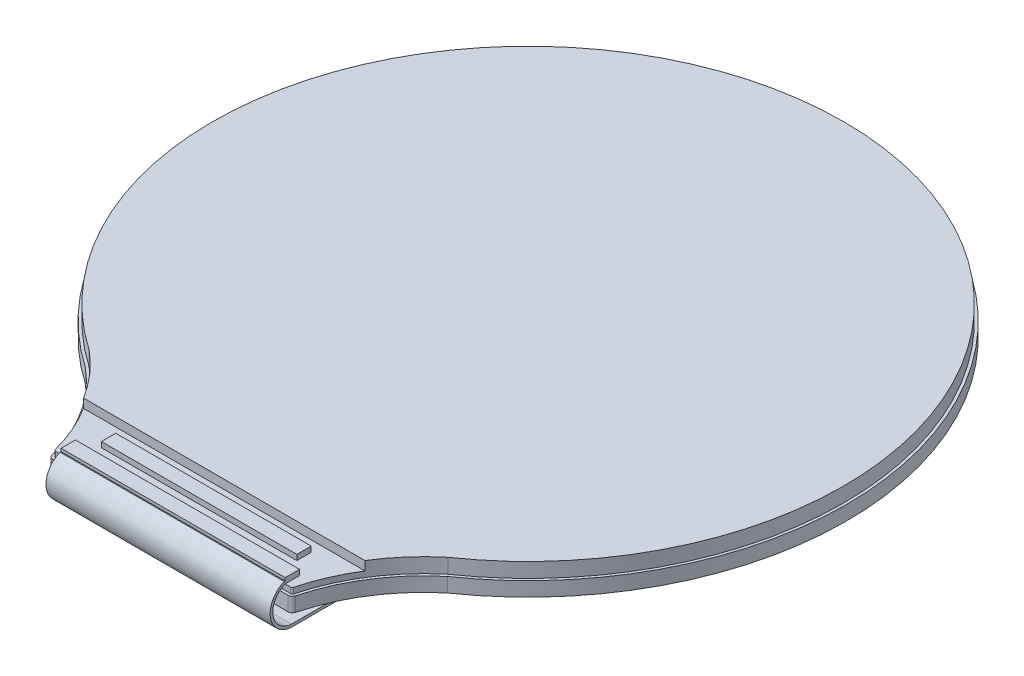
from build123d import *

# Parameters (mm, degrees)
BOSS_EXTRUDE1_DEPTH = 0.8
FILLET1_R           = 0.25
BOSS_EXTRUDE2_DEPTH = 0.82
SKETCH4_W           = 20
SKETCH4_H           = 3
CUT_EXTRUDE1_DEPTH  = 0.5
SKETCH5_W           = 10.9
SKETCH5_H           = 0.8
SKETCH5_W_2         = 12.5
BOSS_EXTRUDE3_DEPTH = 0.3
CUT_EXTRUDE2_DEPTH  = 0.001
BOSS_EXTRUDE4_DEPTH = 6.25
SKETCH9_R           = 0.5
CUT_EXTRUDE3_DEPTH  = 0.2
CUT_EXTRUDE4_DEPTH  = 0.2
FILLET2_R           = 0.5
FILLET3_R           = 0.5
SKETCH11_W          = 0.5
SKETCH11_H          = 2
CUT_EXTRUDE5_DEPTH  = 0.01


with BuildPart() as part:
    # Sketch1 → Boss-Extrude1 (new body)
    with BuildSketch(Plane(origin=(0, 0, 0), x_dir=(1, 0, 0), z_dir=(0, 1, 0))):
        with BuildLine():
            ThreePointArc((-10.098638625, -14.597259946), (-7.990776159, -17.002408255), (-6.75, -19.95))
            Line((-6.75, -19.95), (6.75, -19.95))
            ThreePointArc((6.75, -19.95), (7.990776159, -17.002408255), (10.098638625, -14.597259946))
            ThreePointArc((10.098638625, -14.597259946), (0, 17.75), (-10.098638625, -14.597259946))
        make_face()
    extrude(amount=BOSS_EXTRUDE1_DEPTH)

    # Fillet1
    fillet1_edges = [part.edges().sort_by_distance(p)[0] for p in [
        (6.75, 0.4, 19.95),
        (-6.75, 0.4, 19.95),
    ]]
    fillet(fillet1_edges, radius=FILLET1_R)

    # Sketch2 → Boss-Extrude2 (add)
    with BuildSketch(Plane(origin=(0, 0.8, 0), x_dir=(1, 0, 0), z_dir=(0, 1, 0))):
        with BuildLine():
            Line((-6.555315046, -19.8), (6.555315046, -19.8))
            ThreePointArc((6.555315046, -19.8), (6.616378729, -19.779191076), (6.652029022, -19.725424532))
            ThreePointArc((6.652029022, -19.725424532), (7.917501546, -16.837654003), (10.008059541, -14.477525487))
            ThreePointArc((10.008059541, -14.477525487), (0, 17.6), (-10.008059541, -14.477525487))
            ThreePointArc((-10.008059541, -14.477525487), (-7.917501546, -16.837654003), (-6.652029022, -19.725424532))
            ThreePointArc((-6.652029022, -19.725424532), (-6.616378729, -19.779191076), (-6.555315046, -19.8))
        make_face()
    extrude(amount=BOSS_EXTRUDE2_DEPTH)

    # Sketch4 → Cut-Extrude1 (cut)
    with BuildSketch(Plane(origin=(0, 1.62, 0), x_dir=(1, 0, 0), z_dir=(0, 1, 0))):
        with Locations((0, -18.45)):
            Rectangle(SKETCH4_W, SKETCH4_H)
    extrude(amount=-CUT_EXTRUDE1_DEPTH, mode=Mode.SUBTRACT)

    # Sketch5 → Boss-Extrude3 (add)
    with BuildSketch(Plane(origin=(0, 1.12, 0), x_dir=(1, 0, 0), z_dir=(0, 1, 0))):
        with Locations((0, -17.95)):
            Rectangle(SKETCH5_W, SKETCH5_H)
        with Locations((0, -19.4)):
            Rectangle(SKETCH5_W_2, SKETCH5_H)
    extrude(amount=BOSS_EXTRUDE3_DEPTH)

    # Sketch6 → Cut-Extrude2 (cut)
    with BuildSketch(Plane.XZ):
        with BuildLine():
            Line((-8.115384615, -4), (-7.730769231, -4))
            Line((-7.730769231, -4), (-7.730769231, -5.423878205))
            add(Edge.make_bspline(
                [(-7.730769231, -5.423878205), (-7.713359057, -5.406155063), (-7.678704871, -5.370877927), (-7.623058077, -5.32222958), (-7.565824024, -5.276296318), (-7.506110478, -5.234127463), (-7.443693535, -5.196058157), (-7.379151545, -5.161348193), (-7.312721311, -5.129184198), (-7.266695291, -5.111461223), (-7.243589744, -5.102564103)],
                knots=[0, 0, 0, 0, 7.4507e-05, 0.000148304, 0.000221573, 0.000294602, 0.000367437, 0.000440755, 0.000514409, 0.000588657, 0.000588657, 0.000588657, 0.000588657], degree=3))
            Line((-7.243589744, -5.102564103), (-7.243589744, -5.487179487))
            add(Edge.make_bspline(
                [(-7.243589744, -5.487179487), (-7.269206127, -5.496780125), (-7.322819224, -5.516873513), (-7.4019898, -5.559745442), (-7.484809813, -5.612481575), (-7.55429821, -5.664291811), (-7.608950479, -5.710784433), (-7.647434139, -5.747742278), (-7.683081921, -5.785759046), (-7.71458346, -5.825869891), (-7.742738811, -5.867294969), (-7.767686987, -5.909958484), (-7.789646776, -5.953997327), (-7.801142624, -5.984664925), (-7.806891026, -6)],
                knots=[0, 0, 0, 0, 8.1986e-05, 0.00017159, 0.000269396, 0.000376448, 0.000431289, 0.00048456, 0.000536441, 0.000587499, 0.000637393, 0.000686592, 0.000735686, 0.000784789, 0.000784789, 0.000784789, 0.000784789], degree=3))
            Line((-7.806891026, -6), (-8.115384615, -6))
            Line((-8.115384615, -6), (-8.115384615, -4))
        make_face()
        with BuildLine():
            add(Edge.make_bspline(
                [(-6.256410256, -6), (-6.280217696, -5.999427681), (-6.326568051, -5.998313441), (-6.394092675, -5.988384763), (-6.457597842, -5.972630411), (-6.517095807, -5.949873464), (-6.572889159, -5.921071609), (-6.624192861, -5.884945541), (-6.672194832, -5.843249183), (-6.699906098, -5.810871154), (-6.713942308, -5.794471154)],
                knots=[0, 0, 0, 0, 7.1386e-05, 0.000138981, 0.000204279, 0.000267302, 0.000329663, 0.000392123, 0.00045514, 0.000519821, 0.000519821, 0.000519821, 0.000519821], degree=3))
            add(Edge.make_bspline(
                [(-6.713942308, -5.794471154), (-6.721971706, -5.784027534), (-6.738358302, -5.762713937), (-6.760427113, -5.728273453), (-6.781644323, -5.691739969), (-6.800160808, -5.652232771), (-6.817907535, -5.610442711), (-6.834289066, -5.566253586), (-6.848753793, -5.519415687), (-6.861363445, -5.470142284), (-6.873150438, -5.418358482), (-6.883024897, -5.363937998), (-6.891475748, -5.30701848), (-6.898066216, -5.247662035), (-6.903975014, -5.185984989), (-6.907208178, -5.12168565), (-6.909857159, -5.054909676), (-6.910121795, -5.009484858), (-6.91025641, -4.986378205)],
                knots=[0, 0, 0, 0, 3.9503e-05, 8.0619e-05, 0.00012261, 0.000166155, 0.000211397, 0.000258805, 0.000307466, 0.000358385, 0.000411358, 0.000466758, 0.000524268, 0.000583953, 0.000645906, 0.00071011, 0.00077706, 0.000846375, 0.000846375, 0.000846375, 0.000846375], degree=3))
            add(Edge.make_bspline(
                [(-6.91025641, -4.986378205), (-6.910123823, -4.963271499), (-6.90986394, -4.917980046), (-6.907198306, -4.851338037), (-6.903972131, -4.787172759), (-6.898079986, -4.725492419), (-6.891426237, -4.666147773), (-6.883215148, -4.60929205), (-6.872578164, -4.55512162), (-6.860964857, -4.503420376), (-6.848435539, -4.453937659), (-6.833327892, -4.407184318), (-6.817607087, -4.362444446), (-6.799447896, -4.320600625), (-6.780266949, -4.28104453), (-6.759365469, -4.244138144), (-6.737050241, -4.209484218), (-6.720505114, -4.188058179), (-6.712339744, -4.177483974)],
                knots=[0, 0, 0, 0, 6.9316e-05, 0.000135865, 0.000200069, 0.000262022, 0.000321707, 0.000379217, 0.000434297, 0.00048727, 0.000538189, 0.000587352, 0.000634623, 0.000680391, 0.00072411, 0.000766449, 0.000807565, 0.00084763, 0.00084763, 0.00084763, 0.00084763], degree=3))
            add(Edge.make_bspline(
                [(-6.712339744, -4.177483974), (-6.698431943, -4.161224555), (-6.670977274, -4.129127677), (-6.623506763, -4.087776928), (-6.572285892, -4.052396891), (-6.516593565, -4.024171814), (-6.45738522, -4.001262035), (-6.3937766, -3.986013097), (-6.32643646, -3.976064142), (-6.280085266, -3.974935471), (-6.256410256, -3.974358974)],
                knots=[0, 0, 0, 0, 6.4115e-05, 0.000126566, 0.000188242, 0.000250418, 0.000313441, 0.000378254, 0.000446245, 0.000517231, 0.000517231, 0.000517231, 0.000517231], degree=3))
            add(Edge.make_bspline(
                [(-6.256410256, -3.974358974), (-6.232465306, -3.975047809), (-6.185543935, -3.976397615), (-6.117038725, -3.987102948), (-6.05191365, -4.004240276), (-5.990438846, -4.02875213), (-5.932500524, -4.060395455), (-5.878230627, -4.098928669), (-5.828012004, -4.1449143), (-5.788771275, -4.187788789), (-5.760262586, -4.226505545), (-5.739643325, -4.258394149), (-5.720472285, -4.29299406), (-5.703437474, -4.330736183), (-5.686809514, -4.370661161), (-5.672137696, -4.413526128), (-5.65898602, -4.459031002), (-5.646793755, -4.507214043), (-5.636697895, -4.558359763), (-5.627313567, -4.612021724), (-5.619863903, -4.668448556), (-5.613356728, -4.727475057), (-5.608740431, -4.78935478), (-5.604999189, -4.853860171), (-5.603121636, -4.921196211), (-5.602752435, -4.967013016), (-5.602564103, -4.990384615)],
                knots=[0, 0, 0, 0, 7.1805e-05, 0.000140706, 0.00020747, 0.000273461, 0.000338721, 0.000405088, 0.000472599, 0.00054267, 0.000579049, 0.000616722, 0.00065653, 0.00069758, 0.000740881, 0.00078624, 0.000833403, 0.00088296, 0.000935289, 0.00098976, 0.001046364, 0.001106005, 0.00116789, 0.001232494, 0.001299832, 0.001369949, 0.001369949, 0.001369949, 0.001369949], degree=3))
            add(Edge.make_bspline(
                [(-5.602564103, -4.990384615), (-5.602695692, -5.013357851), (-5.602953589, -5.058382439), (-5.605637797, -5.124756264), (-5.608824425, -5.188657348), (-5.614769652, -5.250199621), (-5.621368662, -5.309281919), (-5.629593905, -5.366008127), (-5.640430063, -5.419965061), (-5.651128206, -5.471752379), (-5.664608128, -5.520863014), (-5.679458743, -5.5675812), (-5.69512742, -5.612221036), (-5.713471985, -5.653848491), (-5.732541897, -5.693319606), (-5.753458016, -5.730219515), (-5.77576956, -5.764875072), (-5.792315163, -5.786300899), (-5.800480769, -5.796875)],
                knots=[0, 0, 0, 0, 6.8915e-05, 0.000135064, 0.000199268, 0.000260822, 0.000320507, 0.000377621, 0.000432701, 0.000485587, 0.000536222, 0.000585385, 0.000632656, 0.000678056, 0.000721775, 0.000764114, 0.00080523, 0.000845294, 0.000845294, 0.000845294, 0.000845294], degree=3))
            add(Edge.make_bspline(
                [(-5.800480769, -5.796875), (-5.814389335, -5.813132855), (-5.841845514, -5.845226646), (-5.889304971, -5.886599997), (-5.940469275, -5.921827975), (-5.99599909, -5.950394985), (-6.055343477, -5.972994929), (-6.11903545, -5.98836653), (-6.186386321, -5.998289296), (-6.232736014, -5.999421632), (-6.256410256, -6)],
                knots=[0, 0, 0, 0, 6.4115e-05, 0.000126566, 0.000188242, 0.000250062, 0.00031346, 0.000378272, 0.000446263, 0.000517249, 0.000517249, 0.000517249, 0.000517249], degree=3))
        make_face()
        with BuildLine():
            add(Edge.make_bspline(
                [(-6.256410256, -5.666666667), (-6.244074324, -5.666136157), (-6.219933376, -5.665097971), (-6.184823503, -5.656632254), (-6.151661361, -5.643519267), (-6.120545281, -5.624261411), (-6.091728132, -5.598186166), (-6.067312377, -5.562952189), (-6.046205369, -5.519763078), (-6.035646151, -5.487472), (-6.030048077, -5.470352564)],
                knots=[0, 0, 0, 0, 3.6966e-05, 7.234e-05, 0.000107753, 0.000143554, 0.000181554, 0.00022347, 0.000271309, 0.00032529, 0.00032529, 0.00032529, 0.00032529], degree=3))
            add(Edge.make_bspline(
                [(-6.030048077, -5.470352564), (-6.026551497, -5.457436105), (-6.01903642, -5.429675215), (-6.01051141, -5.38441298), (-6.003442602, -5.332915663), (-5.99758639, -5.275446586), (-5.992677421, -5.211868318), (-5.989731855, -5.142249731), (-5.987667073, -5.066385187), (-5.987346341, -5.013756948), (-5.987179487, -4.986378205)],
                knots=[0, 0, 0, 0, 4.0132e-05, 8.6255e-05, 0.000138041, 0.000196046, 0.000259529, 0.000329314, 0.000405062, 0.000487197, 0.000487197, 0.000487197, 0.000487197], degree=3))
            add(Edge.make_bspline(
                [(-5.987179487, -4.986378205), (-5.987161379, -4.959132103), (-5.987126666, -4.90690178), (-5.989476176, -4.83198716), (-5.991807619, -4.76369156), (-5.996558042, -4.702019094), (-6.001188096, -4.646875537), (-6.008340993, -4.598577808), (-6.015397388, -4.556683035), (-6.027530885, -4.511311525), (-6.044043928, -4.463608126), (-6.066433453, -4.415139825), (-6.092028856, -4.377296398), (-6.120929179, -4.349523173), (-6.152548815, -4.331310842), (-6.18495109, -4.316809368), (-6.220172356, -4.309539108), (-6.244232295, -4.308312936), (-6.256410256, -4.307692308)],
                knots=[0, 0, 0, 0, 8.1732e-05, 0.000156678, 0.000224845, 0.000286701, 0.000342234, 0.000390791, 0.000433148, 0.000469588, 0.000531548, 0.000584411, 0.000629312, 0.000667857, 0.000703448, 0.000738274, 0.000773951, 0.000810517, 0.000810517, 0.000810517, 0.000810517], degree=3))
            add(Edge.make_bspline(
                [(-6.256410256, -4.307692308), (-6.268605933, -4.308251161), (-6.292730095, -4.309356625), (-6.327794027, -4.317549183), (-6.360909019, -4.33106869), (-6.392234707, -4.349941747), (-6.421078872, -4.376196766), (-6.445512464, -4.41139911), (-6.466613831, -4.454598224), (-6.477173907, -4.486887781), (-6.482772436, -4.50400641)],
                knots=[0, 0, 0, 0, 3.6566e-05, 7.2331e-05, 0.000107373, 0.000143515, 0.000181515, 0.000223431, 0.00027127, 0.000325251, 0.000325251, 0.000325251, 0.000325251], degree=3))
            add(Edge.make_bspline(
                [(-6.482772436, -4.50400641), (-6.486263756, -4.516923915), (-6.493733321, -4.544560491), (-6.502322901, -4.589540582), (-6.509375473, -4.640641815), (-6.51525811, -4.697841463), (-6.52013883, -4.761289181), (-6.523090003, -4.830907185), (-6.525149199, -4.906638403), (-6.52547298, -4.959133037), (-6.525641026, -4.986378205)],
                knots=[0, 0, 0, 0, 4.0132e-05, 8.5861e-05, 0.000137251, 0.000194857, 0.000258341, 0.000328126, 0.000403874, 0.000485608, 0.000485608, 0.000485608, 0.000485608], degree=3))
            add(Edge.make_bspline(
                [(-6.525641026, -4.986378205), (-6.525413648, -5.013621499), (-6.524977804, -5.065842323), (-6.523721733, -5.140928013), (-6.520219482, -5.209290888), (-6.516675159, -5.271199223), (-6.510797662, -5.326327328), (-6.504884367, -5.374956963), (-6.496733827, -5.416755552), (-6.485614863, -5.462220605), (-6.468787452, -5.509798478), (-6.445744029, -5.557829344), (-6.420860175, -5.596382268), (-6.391848323, -5.624292649), (-6.360411507, -5.64336715), (-6.32750697, -5.656728862), (-6.292608623, -5.665047942), (-6.26860887, -5.666121167), (-6.256410256, -5.666666667)],
                knots=[0, 0, 0, 0, 8.1735e-05, 0.000156672, 0.000225256, 0.000287085, 0.000342657, 0.000391557, 0.000433987, 0.000470328, 0.00053191, 0.000584948, 0.000629951, 0.000668772, 0.000704573, 0.000739615, 0.00077499, 0.000811556, 0.000811556, 0.000811556, 0.000811556], degree=3))
        make_face(mode=Mode.SUBTRACT)
        Polygon((-5.423076923, -4), (-5.015224359, -4), (-4.846554487, -4.461538462), (-4.078926282, -4.461538462), (-3.91025641, -4), (-3.5, -4), (-4.256009615, -6), (-4.663461538, -6), align=None)
        Polygon((-4.724358974, -4.794871795), (-4.461538462, -5.512820513), (-4.199519231, -4.794871795), align=None, mode=Mode.SUBTRACT)
        with BuildLine():
            Line((-2.115384615, -4.49599359), (-2.5, -4.538461538))
            add(Edge.make_bspline(
                [(-2.5, -4.538461538), (-2.502538885, -4.520057279), (-2.507337899, -4.48526945), (-2.522285404, -4.437439312), (-2.54216032, -4.396898583), (-2.567843688, -4.363987158), (-2.598596488, -4.338666081), (-2.633777288, -4.320052272), (-2.673970178, -4.309692804), (-2.702132462, -4.308375763), (-2.716746795, -4.307692308)],
                knots=[0, 0, 0, 0, 5.5656e-05, 0.000105201, 0.000149636, 0.000190433, 0.000229419, 0.000268306, 0.000308927, 0.000352745, 0.000352745, 0.000352745, 0.000352745], degree=3))
            add(Edge.make_bspline(
                [(-2.716746795, -4.307692308), (-2.726264256, -4.307910874), (-2.745073481, -4.308342822), (-2.772569696, -4.314517468), (-2.799140429, -4.322985849), (-2.824370626, -4.335985264), (-2.848846756, -4.351743057), (-2.871654346, -4.371896397), (-2.893984694, -4.394780241), (-2.915096397, -4.422003377), (-2.934718225, -4.454817168), (-2.952114602, -4.494579272), (-2.968093633, -4.541438651), (-2.981335457, -4.59596416), (-2.993225745, -4.657615379), (-3.00357851, -4.726575181), (-3.011975253, -4.802890254), (-3.015686916, -4.856286978), (-3.017628205, -4.884214744)],
                knots=[0, 0, 0, 0, 2.8491e-05, 5.6306e-05, 8.4178e-05, 0.00011195, 0.000141175, 0.00017129, 0.000203024, 0.000237003, 0.000274381, 0.000317419, 0.000366958, 0.000422733, 0.000485592, 0.000555285, 0.00063187, 0.000715849, 0.000715849, 0.000715849, 0.000715849], degree=3))
            add(Edge.make_bspline(
                [(-3.017628205, -4.884214744), (-3.005323968, -4.871008445), (-2.981064379, -4.84497031), (-2.94088495, -4.81080931), (-2.898104216, -4.782088841), (-2.852941039, -4.758939133), (-2.805866578, -4.740025738), (-2.75610689, -4.727584847), (-2.704354816, -4.719049159), (-2.668972825, -4.718318837), (-2.651041667, -4.717948718)],
                knots=[0, 0, 0, 0, 5.4116e-05, 0.000106698, 0.000157812, 0.000208344, 0.000258712, 0.000309631, 0.000361931, 0.000415671, 0.000415671, 0.000415671, 0.000415671], degree=3))
            add(Edge.make_bspline(
                [(-2.651041667, -4.717948718), (-2.631389048, -4.718527555), (-2.592586595, -4.719670419), (-2.535398826, -4.727541076), (-2.480618992, -4.74213349), (-2.42736586, -4.76048138), (-2.37676676, -4.785867209), (-2.327937001, -4.815968157), (-2.281307737, -4.8519055), (-2.237335783, -4.892933918), (-2.196359678, -4.937765794), (-2.160973039, -4.986895093), (-2.131354173, -5.039475315), (-2.106096161, -5.094759727), (-2.087522201, -5.153781745), (-2.073743079, -5.215815561), (-2.065754226, -5.281309026), (-2.064660641, -5.32610045), (-2.064102564, -5.348958333)],
                knots=[0, 0, 0, 0, 5.8961e-05, 0.000116414, 0.000172676, 0.000228813, 0.000285074, 0.000342109, 0.000400686, 0.000461354, 0.000522342, 0.000582609, 0.000642539, 0.000703151, 0.000764601, 0.000827786, 0.00089358, 0.000962147, 0.000962147, 0.000962147, 0.000962147], degree=3))
            add(Edge.make_bspline(
                [(-2.064102564, -5.348958333), (-2.064613441, -5.372756322), (-2.065615563, -5.419437794), (-2.074271451, -5.487520331), (-2.087794134, -5.552194191), (-2.106887038, -5.613418529), (-2.132376259, -5.670871787), (-2.162948424, -5.724832269), (-2.198735621, -5.775474654), (-2.240478353, -5.821470169), (-2.285872873, -5.863567601), (-2.334837533, -5.900203546), (-2.387094365, -5.930820341), (-2.442178805, -5.956264113), (-2.500504503, -5.975859516), (-2.561698574, -5.989823589), (-2.625820555, -5.998482045), (-2.669576922, -5.999487094), (-2.691907051, -6)],
                knots=[0, 0, 0, 0, 7.1369e-05, 0.000139996, 0.00020553, 0.000269392, 0.000331997, 0.000393716, 0.000455193, 0.000517611, 0.000579705, 0.000640683, 0.000700668, 0.000761082, 0.000822402, 0.000884893, 0.000949148, 0.001016114, 0.001016114, 0.001016114, 0.001016114], degree=3))
            add(Edge.make_bspline(
                [(-2.691907051, -6), (-2.716253581, -5.999332976), (-2.763994259, -5.998025022), (-2.833921865, -5.986962012), (-2.900361098, -5.968587282), (-2.963341859, -5.942473286), (-3.023497146, -5.910148387), (-3.079962711, -5.869539804), (-3.132759959, -5.821597219), (-3.182613405, -5.766773121), (-3.227985644, -5.703456773), (-3.266611797, -5.630270099), (-3.299468717, -5.54791691), (-3.325989358, -5.456217149), (-3.346712225, -5.35519528), (-3.361014872, -5.24485296), (-3.370585368, -5.125168416), (-3.37138179, -5.042221171), (-3.371794872, -4.999198718)],
                knots=[0, 0, 0, 0, 7.3006e-05, 0.000143156, 0.000211782, 0.000279338, 0.000347284, 0.000416213, 0.000487415, 0.000560881, 0.000638147, 0.00072042, 0.000808506, 0.000903715, 0.001006411, 0.00111758, 0.001237326, 0.001366363, 0.001366363, 0.001366363, 0.001366363], degree=3))
            add(Edge.make_bspline(
                [(-3.371794872, -4.999198718), (-3.37119747, -4.955510818), (-3.370043264, -4.871103974), (-3.360740665, -4.749249047), (-3.34599274, -4.636743389), (-3.324386686, -4.533750641), (-3.297039751, -4.440073605), (-3.263486735, -4.355599696), (-3.223525052, -4.280555236), (-3.177015193, -4.214981352), (-3.125332685, -4.158433263), (-3.070305111, -4.109047004), (-3.011304768, -4.067579812), (-2.948937943, -4.032964991), (-2.882230101, -4.007049674), (-2.812115441, -3.988272886), (-2.738402342, -3.976109923), (-2.68794914, -3.974949721), (-2.662259615, -3.974358974)],
                knots=[0, 0, 0, 0, 0.000131049, 0.000253192, 0.0003664, 0.000471221, 0.000568577, 0.000658821, 0.000743428, 0.000823022, 0.000899318, 0.000972814, 0.001044399, 0.001115223, 0.001186273, 0.001258483, 0.001332716, 0.001409723, 0.001409723, 0.001409723, 0.001409723], degree=3))
            add(Edge.make_bspline(
                [(-2.662259615, -3.974358974), (-2.643815227, -3.974739444), (-2.607626478, -3.975485942), (-2.554637656, -3.981465168), (-2.504380387, -3.991921468), (-2.456869827, -4.006317817), (-2.412159099, -4.024793351), (-2.370262568, -4.047324663), (-2.331015071, -4.073996804), (-2.294573287, -4.104958771), (-2.260871802, -4.139732904), (-2.230537694, -4.178773497), (-2.203323097, -4.221704772), (-2.179242133, -4.268801146), (-2.158570445, -4.31997805), (-2.140370271, -4.374886312), (-2.126115884, -4.434053897), (-2.119024877, -4.474982402), (-2.115384615, -4.49599359)],
                knots=[0, 0, 0, 0, 5.5325e-05, 0.00010855, 0.000159702, 0.000209129, 0.000257267, 0.00030459, 0.000351595, 0.000399354, 0.000447805, 0.000496613, 0.000547406, 0.000600085, 0.000655066, 0.000712839, 0.000773474, 0.000837438, 0.000837438, 0.000837438, 0.000837438], degree=3))
        make_face()
        with BuildLine():
            add(Edge.make_bspline(
                [(-2.987179487, -5.339342949), (-2.987056721, -5.352050026), (-2.986818126, -5.376746232), (-2.981880745, -5.412411004), (-2.975993887, -5.446117587), (-2.965987087, -5.477335279), (-2.954382211, -5.506949167), (-2.938652808, -5.533623725), (-2.921705372, -5.559044064), (-2.894389474, -5.588154359), (-2.857510646, -5.61957972), (-2.807856894, -5.646296785), (-2.755202225, -5.664061251), (-2.718492578, -5.665791349), (-2.699919872, -5.666666667)],
                knots=[0, 0, 0, 0, 3.808e-05, 7.4008e-05, 0.000107874, 0.00014057, 0.00017219, 0.000203049, 0.000233279, 0.000263624, 0.000322513, 0.000377733, 0.000431964, 0.000487497, 0.000487497, 0.000487497, 0.000487497], degree=3))
            add(Edge.make_bspline(
                [(-2.699919872, -5.666666667), (-2.682598606, -5.66588454), (-2.648884641, -5.664362215), (-2.600822677, -5.6506291), (-2.557206725, -5.628626617), (-2.525253274, -5.602773612), (-2.503048227, -5.577566736), (-2.488401583, -5.555453924), (-2.476105375, -5.530672196), (-2.466057663, -5.502959403), (-2.458135959, -5.472656522), (-2.452530895, -5.439413282), (-2.449476929, -5.403503356), (-2.44897604, -5.378611326), (-2.448717949, -5.365785256)],
                knots=[0, 0, 0, 0, 5.187e-05, 0.00010096, 0.000148621, 0.000197614, 0.000223167, 0.000249169, 0.00027694, 0.000305967, 0.000337452, 0.00037078, 0.00040698, 0.00044546, 0.00044546, 0.00044546, 0.00044546], degree=3))
            add(Edge.make_bspline(
                [(-2.448717949, -5.365785256), (-2.448929741, -5.352688691), (-2.449339064, -5.327377418), (-2.453014916, -5.290682881), (-2.458869751, -5.256763729), (-2.467179819, -5.225387523), (-2.478674793, -5.197007665), (-2.491452997, -5.170625706), (-2.507949675, -5.147733559), (-2.531680237, -5.120523679), (-2.566577581, -5.09300168), (-2.613392075, -5.068140981), (-2.665731003, -5.054001473), (-2.702108756, -5.052203536), (-2.720753205, -5.051282051)],
                knots=[0, 0, 0, 0, 3.9281e-05, 7.5917e-05, 0.000110498, 0.000142474, 0.000173052, 0.000202257, 0.000230156, 0.000257405, 0.000310402, 0.00036237, 0.000415534, 0.000471431, 0.000471431, 0.000471431, 0.000471431], degree=3))
            add(Edge.make_bspline(
                [(-2.720753205, -5.051282051), (-2.738884041, -5.052003264), (-2.774261904, -5.053410535), (-2.824742969, -5.068089985), (-2.870732951, -5.091396702), (-2.904670016, -5.118101582), (-2.928828706, -5.143517172), (-2.944404163, -5.165314905), (-2.95769774, -5.189100798), (-2.968609602, -5.21502296), (-2.976922593, -5.243122575), (-2.982876194, -5.27329911), (-2.986553983, -5.305598251), (-2.986966407, -5.327847689), (-2.987179487, -5.339342949)],
                knots=[0, 0, 0, 0, 5.4266e-05, 0.000105886, 0.000156235, 0.00020817, 0.00023453, 0.000261217, 0.000288301, 0.000316131, 0.000345411, 0.000376054, 0.000408307, 0.000442783, 0.000442783, 0.000442783, 0.000442783], degree=3))
        make_face(mode=Mode.SUBTRACT)
        with BuildLine():
            Line((-1.448717949, -4.743589744), (-1.833333333, -4.615384615))
            add(Edge.make_bspline(
                [(-1.833333333, -4.615384615), (-1.825520314, -4.5901642), (-1.810219965, -4.540774693), (-1.782063337, -4.470024095), (-1.750072731, -4.404259121), (-1.714424748, -4.343474759), (-1.67492646, -4.287923466), (-1.632097762, -4.237046948), (-1.584884044, -4.191687005), (-1.5342323, -4.151004004), (-1.479892618, -4.115218077), (-1.421946757, -4.08427476), (-1.360498845, -4.058245683), (-1.295462212, -4.037014862), (-1.227080793, -4.020056766), (-1.155070018, -4.008844944), (-1.079756568, -4.001246068), (-1.02833186, -4.000421941), (-1.002003205, -4)],
                knots=[0, 0, 0, 0, 7.9186e-05, 0.000155071, 0.000228177, 0.0002984, 0.000366212, 0.000432439, 0.000497607, 0.000562304, 0.000627086, 0.000692509, 0.000759109, 0.000827017, 0.000897563, 0.000970213, 0.001045479, 0.001124442, 0.001124442, 0.001124442, 0.001124442], degree=3))
            add(Edge.make_bspline(
                [(-1.002003205, -4), (-0.969505727, -4.000671818), (-0.905582216, -4.001993304), (-0.812101679, -4.015301245), (-0.723013082, -4.0360532), (-0.638216395, -4.064824513), (-0.55811454, -4.102814818), (-0.482512779, -4.149039451), (-0.411506907, -4.203736657), (-0.345219882, -4.265894606), (-0.285134529, -4.335463389), (-0.23273347, -4.411839737), (-0.188153634, -4.494102968), (-0.151948742, -4.582661963), (-0.123918009, -4.677304487), (-0.104195242, -4.778046692), (-0.091870352, -4.884843796), (-0.090464897, -4.95803156), (-0.08974359, -4.995592949)],
                knots=[0, 0, 0, 0, 9.7438e-05, 0.000191664, 0.000282623, 0.000371566, 0.00045974, 0.000548035, 0.000636903, 0.000728168, 0.000820207, 0.000912111, 0.00100551, 0.00110037, 0.001198609, 0.001301146, 0.001407994, 0.001520645, 0.001520645, 0.001520645, 0.001520645], degree=3))
            add(Edge.make_bspline(
                [(-0.08974359, -4.995592949), (-0.090480256, -5.035152841), (-0.091917357, -5.112326972), (-0.104010592, -5.224628303), (-0.124112265, -5.33016394), (-0.151232624, -5.42917023), (-0.187814573, -5.521000445), (-0.231127377, -5.606615872), (-0.283903235, -5.684686464), (-0.343333458, -5.756041695), (-0.409632995, -5.819382975), (-0.481284052, -5.874713492), (-0.558139734, -5.921208817), (-0.639808357, -5.959786765), (-0.726690399, -5.989262708), (-0.818585613, -6.010608745), (-0.915526258, -6.023011248), (-0.981802269, -6.024752441), (-1.015625, -6.025641026)],
                knots=[0, 0, 0, 0, 0.000118657, 0.000231479, 0.000338341, 0.000440702, 0.000538908, 0.000634413, 0.000727974, 0.000820975, 0.000912501, 0.001002492, 0.001092022, 0.001181455, 0.001272931, 0.001366713, 0.001464063, 0.00156552, 0.00156552, 0.00156552, 0.00156552], degree=3))
            add(Edge.make_bspline(
                [(-1.015625, -6.025641026), (-1.045165379, -6.024901071), (-1.103083222, -6.023450292), (-1.187873097, -6.013474438), (-1.268363489, -5.996286832), (-1.344461457, -5.972012504), (-1.416696149, -5.941776123), (-1.484207328, -5.903726781), (-1.547793453, -5.859224429), (-1.58608977, -5.82441467), (-1.60536859, -5.806891026)],
                knots=[0, 0, 0, 0, 8.8615e-05, 0.000173742, 0.000255701, 0.000335146, 0.000413057, 0.000490184, 0.000567218, 0.00064531, 0.00064531, 0.00064531, 0.00064531], degree=3))
            add(Edge.make_bspline(
                [(-1.60536859, -5.806891026), (-1.616544636, -5.795743659), (-1.639159247, -5.773187082), (-1.669329337, -5.735089256), (-1.698112612, -5.694048801), (-1.724345259, -5.649228151), (-1.748454817, -5.600862516), (-1.77032669, -5.549151716), (-1.790634692, -5.493998121), (-1.801907413, -5.455601616), (-1.807692308, -5.435897436)],
                knots=[0, 0, 0, 0, 4.7318e-05, 9.5748e-05, 0.000145538, 0.000197622, 0.000251373, 0.000307557, 0.000365987, 0.000427579, 0.000427579, 0.000427579, 0.000427579], degree=3))
            Line((-1.807692308, -5.435897436), (-1.423076923, -5.358974359))
            add(Edge.make_bspline(
                [(-1.423076923, -5.358974359), (-1.419807885, -5.371589801), (-1.413368739, -5.396438912), (-1.400339361, -5.432145119), (-1.385396045, -5.466029427), (-1.366866262, -5.497251138), (-1.347214313, -5.527239012), (-1.323888916, -5.554444656), (-1.298878953, -5.580218264), (-1.271100739, -5.603388907), (-1.241351284, -5.624291211), (-1.209930496, -5.642679836), (-1.176761506, -5.65802887), (-1.142094953, -5.670313654), (-1.106047058, -5.680639684), (-1.068274167, -5.687012761), (-1.029106957, -5.691907089), (-1.002420711, -5.692172201), (-0.988782051, -5.692307692)],
                knots=[0, 0, 0, 0, 3.9074e-05, 7.6966e-05, 0.000113903, 0.000149981, 0.000185762, 0.000221311, 0.00025729, 0.000293404, 0.000329639, 0.000366264, 0.000402473, 0.000439098, 0.000476521, 0.000514792, 0.000553904, 0.000594787, 0.000594787, 0.000594787, 0.000594787], degree=3))
            add(Edge.make_bspline(
                [(-0.988782051, -5.692307692), (-0.970053949, -5.69191745), (-0.933370001, -5.691153058), (-0.879909501, -5.683064202), (-0.829027078, -5.671390223), (-0.780904341, -5.653964189), (-0.735675066, -5.631354798), (-0.692680651, -5.604489206), (-0.65301685, -5.572070368), (-0.615738934, -5.53516514), (-0.582323019, -5.49227131), (-0.552917158, -5.443559934), (-0.528530219, -5.38842507), (-0.508729644, -5.327422987), (-0.493144989, -5.260404153), (-0.482016138, -5.187283937), (-0.475861594, -5.108011924), (-0.474870656, -5.05316205), (-0.474358974, -5.024839744)],
                knots=[0, 0, 0, 0, 5.6141e-05, 0.000109967, 0.000161859, 0.000212553, 0.00026308, 0.00031332, 0.000364315, 0.000416441, 0.000470379, 0.000526996, 0.000586713, 0.00065082, 0.000719137, 0.000792912, 0.000872498, 0.000957467, 0.000957467, 0.000957467, 0.000957467], degree=3))
            add(Edge.make_bspline(
                [(-0.474358974, -5.024839744), (-0.474865977, -4.994782037), (-0.475842893, -4.936865466), (-0.481991342, -4.853324688), (-0.493207589, -4.776494555), (-0.508503769, -4.706339797), (-0.528529842, -4.642849899), (-0.552951603, -4.585990324), (-0.581514972, -4.535464412), (-0.615393036, -4.492135005), (-0.652579196, -4.454756233), (-0.692229645, -4.422112307), (-0.734742191, -4.394644658), (-0.77979981, -4.371973453), (-0.827773112, -4.354850736), (-0.878233373, -4.342425695), (-0.931375165, -4.334528741), (-0.967786895, -4.333737387), (-0.986378205, -4.333333333)],
                knots=[0, 0, 0, 0, 9.0176e-05, 0.000173756, 0.000251096, 0.000322928, 0.000388942, 0.000450492, 0.000508286, 0.00056254, 0.00061495, 0.000666198, 0.000716316, 0.000766485, 0.000817178, 0.000868775, 0.000922205, 0.000977946, 0.000977946, 0.000977946, 0.000977946], degree=3))
            add(Edge.make_bspline(
                [(-0.986378205, -4.333333333), (-1.000142556, -4.333676732), (-1.02720811, -4.334351975), (-1.067213084, -4.338637689), (-1.105609701, -4.346816357), (-1.142585899, -4.357631165), (-1.178285344, -4.371200558), (-1.212163501, -4.388607361), (-1.244886908, -4.408613897), (-1.275776582, -4.432060023), (-1.305246149, -4.458382776), (-1.332124144, -4.488805318), (-1.357055715, -4.522596665), (-1.379724568, -4.559982644), (-1.400888142, -4.600643246), (-1.418894219, -4.645211983), (-1.435668493, -4.692968605), (-1.444292155, -4.72642131), (-1.448717949, -4.743589744)],
                knots=[0, 0, 0, 0, 4.1297e-05, 8.1205e-05, 0.000120492, 0.000158906, 0.000196702, 0.000234866, 0.000273003, 0.000311625, 0.000351053, 0.000391344, 0.000433173, 0.000476874, 0.000522387, 0.000570525, 0.000620952, 0.000674117, 0.000674117, 0.000674117, 0.000674117], degree=3))
        make_face()
        with BuildLine():
            Line((1.08974359, -4.743589744), (1.08974359, -5.076923077))
            Line((1.08974359, -5.076923077), (0.217948718, -5.076923077))
            Line((0.217948718, -5.076923077), (0.217948718, -4.273237179))
            add(Edge.make_bspline(
                [(0.217948718, -4.273237179), (0.228920749, -4.263357131), (0.2513498, -4.243160314), (0.287945329, -4.214677749), (0.328233559, -4.187485482), (0.371970939, -4.1610328), (0.419247984, -4.135532609), (0.469876128, -4.110629755), (0.523948782, -4.086567781), (0.600415421, -4.056425239), (0.698843661, -4.023627662), (0.819174151, -3.995109103), (0.940456534, -3.977617545), (1.02157815, -3.975444458), (1.062099359, -3.974358974)],
                knots=[0, 0, 0, 0, 4.4285e-05, 9.0527e-05, 0.000138977, 0.000190028, 0.00024381, 0.000300071, 0.000359259, 0.000421306, 0.000546607, 0.00067012, 0.000791881, 0.000913405, 0.000913405, 0.000913405, 0.000913405], degree=3))
            add(Edge.make_bspline(
                [(1.062099359, -3.974358974), (1.087483344, -3.974745977), (1.137522729, -3.975508873), (1.211413454, -3.981482172), (1.282769234, -3.992143234), (1.351829225, -4.005775552), (1.418124825, -4.024486217), (1.482121851, -4.046736941), (1.543338381, -4.073889758), (1.602406462, -4.103991941), (1.657930089, -4.138763433), (1.71084738, -4.176070397), (1.75917473, -4.218272218), (1.804839334, -4.262887325), (1.845930088, -4.311864752), (1.884513977, -4.36347692), (1.918227402, -4.419517539), (1.949047647, -4.478225874), (1.97627529, -4.539370044), (1.999288261, -4.602436846), (2.019453368, -4.666546556), (2.036029543, -4.731914567), (2.048203273, -4.798756002), (2.057667068, -4.86676089), (2.062750005, -4.93635432), (2.06364865, -4.983165893), (2.064102564, -5.006810897)],
                knots=[0, 0, 0, 0, 7.6148e-05, 0.000150111, 0.000222182, 0.000292504, 0.000361131, 0.000428668, 0.000495586, 0.000561886, 0.000627372, 0.000691969, 0.000755893, 0.000819635, 0.000883298, 0.000947483, 0.001012759, 0.001079244, 0.001146323, 0.001213379, 0.001280539, 0.001347877, 0.001415534, 0.001484263, 0.001553769, 0.001624711, 0.001624711, 0.001624711, 0.001624711], degree=3))
            add(Edge.make_bspline(
                [(2.064102564, -5.006810897), (2.063734793, -5.032331506), (2.063009756, -5.082643654), (2.056750084, -5.157002241), (2.047055584, -5.229190278), (2.032260493, -5.299037407), (2.014572219, -5.367053406), (1.991773904, -5.432694632), (1.966063868, -5.496669776), (1.935385758, -5.557777856), (1.901611071, -5.616442214), (1.863393552, -5.671395376), (1.821481277, -5.72282702), (1.776354512, -5.771197141), (1.726652978, -5.81525021), (1.673607988, -5.856128679), (1.617216566, -5.894291902), (1.576863354, -5.915815937), (1.556490385, -5.926682692)],
                knots=[0, 0, 0, 0, 7.6549e-05, 0.00015091, 0.000223718, 0.000294906, 0.000364974, 0.000434404, 0.000503223, 0.000571667, 0.000639352, 0.000706145, 0.00077222, 0.000838258, 0.000904368, 0.000971202, 0.001039095, 0.001108323, 0.001108323, 0.001108323, 0.001108323], degree=3))
            add(Edge.make_bspline(
                [(1.556490385, -5.926682692), (1.540315683, -5.934694336), (1.507575236, -5.950911314), (1.45542905, -5.970659255), (1.400693897, -5.988108694), (1.342730945, -6.001438373), (1.282157987, -6.012230468), (1.218675833, -6.020433959), (1.152167416, -6.024614879), (1.106842568, -6.025294517), (1.083733974, -6.025641026)],
                knots=[0, 0, 0, 0, 5.4121e-05, 0.00010955, 0.000167078, 0.000226356, 0.000287813, 0.000351619, 0.000418271, 0.000487601, 0.000487601, 0.000487601, 0.000487601], degree=3))
            add(Edge.make_bspline(
                [(1.083733974, -6.025641026), (1.053938974, -6.025197226), (0.995993209, -6.024334119), (0.91151262, -6.017142211), (0.832005347, -6.004747195), (0.757360669, -5.987675884), (0.687739394, -5.96572671), (0.623261374, -5.938742851), (0.563530858, -5.907267349), (0.50941297, -5.870038755), (0.459807836, -5.828989874), (0.414844899, -5.784070774), (0.374506062, -5.735214922), (0.338764637, -5.682668147), (0.307901934, -5.626213251), (0.281365903, -5.566365115), (0.259523538, -5.502669392), (0.248967607, -5.458433841), (0.243589744, -5.435897436)],
                knots=[0, 0, 0, 0, 8.9375e-05, 0.000173818, 0.000254112, 0.000330596, 0.000403326, 0.000472822, 0.000540035, 0.000605487, 0.000669505, 0.000732964, 0.000795854, 0.000859305, 0.000923319, 0.000988608, 0.001055504, 0.001124982, 0.001124982, 0.001124982, 0.001124982], degree=3))
            Line((0.243589744, -5.435897436), (0.628205128, -5.358974359))
            add(Edge.make_bspline(
                [(0.628205128, -5.358974359), (0.632010292, -5.371597414), (0.63951781, -5.396502465), (0.654130963, -5.432216585), (0.670767206, -5.465988876), (0.690421193, -5.497286265), (0.711296502, -5.527298466), (0.735836869, -5.554323061), (0.761650906, -5.580374659), (0.790633218, -5.603403524), (0.821510328, -5.624173564), (0.853953264, -5.642900165), (0.888689949, -5.658087565), (0.925235195, -5.670307305), (0.963410005, -5.680685139), (1.00371268, -5.687067535), (1.045690599, -5.691881099), (1.07437065, -5.692163971), (1.088942308, -5.692307692)],
                knots=[0, 0, 0, 0, 3.9532e-05, 7.7995e-05, 0.000115621, 0.000152315, 0.000188782, 0.000225114, 0.000261661, 0.000298702, 0.000335927, 0.000373247, 0.000410916, 0.000449432, 0.000488788, 0.000529427, 0.000571725, 0.000615411, 0.000615411, 0.000615411, 0.000615411], degree=3))
            add(Edge.make_bspline(
                [(1.088942308, -5.692307692), (1.110997021, -5.691719265), (1.154038675, -5.6905709), (1.216873752, -5.683077569), (1.276152883, -5.669746246), (1.332031079, -5.651358227), (1.384610781, -5.627755918), (1.433181474, -5.598059001), (1.47895254, -5.564024688), (1.520621494, -5.524079974), (1.5584105, -5.479290535), (1.591123645, -5.42912213), (1.618357198, -5.373736924), (1.64066303, -5.313413022), (1.658423232, -5.248147909), (1.670471528, -5.177710545), (1.678343665, -5.102208989), (1.679098185, -5.050101361), (1.679487179, -5.023237179)],
                knots=[0, 0, 0, 0, 6.6165e-05, 0.000129127, 0.000189487, 0.000248146, 0.000305343, 0.000361959, 0.00041861, 0.000476137, 0.000534718, 0.000594058, 0.000655335, 0.000719482, 0.000786738, 0.000857941, 0.000933645, 0.00101421, 0.00101421, 0.00101421, 0.00101421], degree=3))
            add(Edge.make_bspline(
                [(1.679487179, -5.023237179), (1.679082042, -4.994373228), (1.678294633, -4.938274455), (1.670621961, -4.856995115), (1.658035431, -4.78125355), (1.639866778, -4.71121327), (1.617409094, -4.646451567), (1.589063957, -4.587403502), (1.555972853, -4.533863512), (1.517445934, -4.486393134), (1.475369735, -4.444119461), (1.429651972, -4.407570706), (1.380608772, -4.376898963), (1.328717275, -4.351451269), (1.273463515, -4.331772055), (1.215039713, -4.317830827), (1.153435351, -4.309211406), (1.111273334, -4.308205809), (1.08974359, -4.307692308)],
                knots=[0, 0, 0, 0, 8.6572e-05, 0.000168257, 0.000244661, 0.000316666, 0.000385093, 0.000449962, 0.000512772, 0.000573465, 0.000632957, 0.000691397, 0.000748644, 0.000806161, 0.000864454, 0.000924215, 0.000986088, 0.001050652, 0.001050652, 0.001050652, 0.001050652], degree=3))
            add(Edge.make_bspline(
                [(1.08974359, -4.307692308), (1.067939712, -4.308310388), (1.024123371, -4.309552461), (0.958408865, -4.319697273), (0.892541315, -4.335643148), (0.827661397, -4.358197831), (0.765034872, -4.384632883), (0.706472261, -4.414542513), (0.651810316, -4.44610195), (0.618776358, -4.470700213), (0.602564103, -4.482772436)],
                knots=[0, 0, 0, 0, 6.5383e-05, 0.000131392, 0.000199023, 0.000268453, 0.00033721, 0.000402788, 0.000465658, 0.000526251, 0.000526251, 0.000526251, 0.000526251], degree=3))
            Line((0.602564103, -4.482772436), (0.602564103, -4.743589744))
            Line((0.602564103, -4.743589744), (1.08974359, -4.743589744))
        make_face()
        with BuildLine():
            Line((4.756410256, -6), (4.022836538, -6))
            add(Edge.make_bspline(
                [(4.022836538, -6), (4.002801449, -6.000010386), (3.963788477, -6.000030611), (3.90717044, -5.997681785), (3.854225296, -5.995319175), (3.805105011, -5.990589746), (3.759639172, -5.985632466), (3.717746192, -5.979356176), (3.679690711, -5.971312424), (3.655692946, -5.964968963), (3.644230769, -5.961939103)],
                knots=[0, 0, 0, 0, 6.0097e-05, 0.000117024, 0.000169983, 0.000219059, 0.000265028, 0.000307185, 0.00034608, 0.000381645, 0.000381645, 0.000381645, 0.000381645], degree=3))
            add(Edge.make_bspline(
                [(3.644230769, -5.961939103), (3.629871829, -5.957324493), (3.601365054, -5.948163119), (3.559976856, -5.931054706), (3.519973929, -5.9120498), (3.481594425, -5.89015351), (3.444845971, -5.865886333), (3.409852986, -5.838719966), (3.376156322, -5.809554194), (3.333298508, -5.767201487), (3.284359577, -5.708445947), (3.232857171, -5.630814942), (3.189144622, -5.545515628), (3.158879281, -5.469215742), (3.13878978, -5.404077207), (3.125591799, -5.351787764), (3.114356398, -5.296725493), (3.105795749, -5.238769311), (3.098484727, -5.178269296), (3.093226043, -5.114931233), (3.090625005, -5.048766513), (3.090041363, -5.003741137), (3.08974359, -4.980769231)],
                knots=[0, 0, 0, 0, 4.523e-05, 8.9795e-05, 0.000134235, 0.000178015, 0.00022224, 0.000266234, 0.000310821, 0.000355866, 0.000446867, 0.00053965, 0.000634799, 0.000733897, 0.000785474, 0.000839209, 0.000895624, 0.000953986, 0.001014911, 0.001078426, 0.001144591, 0.001213512, 0.001213512, 0.001213512, 0.001213512], degree=3))
            add(Edge.make_bspline(
                [(3.08974359, -4.980769231), (3.090535614, -4.941077954), (3.092069671, -4.864200643), (3.103155737, -4.753251008), (3.121884788, -4.650567632), (3.141253383, -4.586392907), (3.150641026, -4.555288462)],
                knots=[0, 0, 0, 0, 0.000119058, 0.000230601, 0.000334165, 0.000431573, 0.000431573, 0.000431573, 0.000431573], degree=3))
            add(Edge.make_bspline(
                [(3.150641026, -4.555288462), (3.157004695, -4.537457746), (3.169564317, -4.502266249), (3.1912388, -4.451443981), (3.21483301, -4.403252196), (3.240596483, -4.357813386), (3.268257197, -4.31485154), (3.297863143, -4.27437709), (3.329437482, -4.236475795), (3.352392085, -4.213382074), (3.363782051, -4.201923077)],
                knots=[0, 0, 0, 0, 5.6787e-05, 0.000112076, 0.00016565, 0.000217679, 0.000268688, 0.000318852, 0.000368046, 0.000416497, 0.000416497, 0.000416497, 0.000416497], degree=3))
            add(Edge.make_bspline(
                [(3.363782051, -4.201923077), (3.382310985, -4.185202924), (3.420234231, -4.150981717), (3.487453501, -4.108884592), (3.562730447, -4.071225696), (3.617531306, -4.052261863), (3.645833333, -4.042467949)],
                knots=[0, 0, 0, 0, 7.4744e-05, 0.000152979, 0.000237011, 0.000326762, 0.000326762, 0.000326762, 0.000326762], degree=3))
            add(Edge.make_bspline(
                [(3.645833333, -4.042467949), (3.657273659, -4.038957368), (3.681017464, -4.03167134), (3.718658001, -4.02383331), (3.758890913, -4.0158323), (3.801981427, -4.010039294), (3.847833447, -4.005712376), (3.896465638, -4.002529129), (3.947900175, -4.000525527), (3.983171234, -4.000177773), (4.001201923, -4)],
                knots=[0, 0, 0, 0, 3.5881e-05, 7.447e-05, 0.000115251, 0.000158935, 0.000204821, 0.000253404, 0.000305126, 0.000359218, 0.000359218, 0.000359218, 0.000359218], degree=3))
            Line((4.001201923, -4), (4.756410256, -4))
            Line((4.756410256, -4), (4.756410256, -6))
        make_face()
        with BuildLine():
            Line((4.371794872, -5.666666667), (4.371794872, -4.333333333))
            Line((4.371794872, -4.333333333), (4.055288462, -4.333333333))
            add(Edge.make_bspline(
                [(4.055288462, -4.333333333), (4.040999027, -4.333446658), (4.013486406, -4.333664852), (3.97367494, -4.334305988), (3.937088537, -4.336041666), (3.903535536, -4.337839545), (3.873103288, -4.340809955), (3.845659378, -4.343731467), (3.821356571, -4.347818602), (3.806346561, -4.351044931), (3.799278846, -4.352564103)],
                knots=[0, 0, 0, 0, 4.287e-05, 8.2542e-05, 0.000119436, 0.000152749, 0.000183327, 0.000211156, 0.000235526, 0.000257213, 0.000257213, 0.000257213, 0.000257213], degree=3))
            add(Edge.make_bspline(
                [(3.799278846, -4.352564103), (3.782725457, -4.356981368), (3.750483822, -4.365585036), (3.705213306, -4.384765087), (3.664249322, -4.407903721), (3.626905848, -4.435726934), (3.593251648, -4.470889039), (3.564523674, -4.515858615), (3.537936691, -4.569491178), (3.519729919, -4.620830954), (3.506661133, -4.66668644), (3.497814637, -4.705174082), (3.49082349, -4.746813819), (3.484810193, -4.791441313), (3.479951305, -4.838999177), (3.476927875, -4.889659148), (3.474864365, -4.943359216), (3.474530629, -4.980232945), (3.474358974, -4.999198718)],
                knots=[0, 0, 0, 0, 5.1346e-05, 0.000100009, 0.000147019, 0.000192211, 0.000239252, 0.000292144, 0.00035163, 0.000418548, 0.000455199, 0.000494658, 0.000536944, 0.000581819, 0.000629737, 0.00068032, 0.000734043, 0.00079094, 0.00079094, 0.00079094, 0.00079094], degree=3))
            add(Edge.make_bspline(
                [(3.474358974, -4.999198718), (3.474529308, -5.01816455), (3.474859277, -5.054904939), (3.476919638, -5.108204583), (3.479926029, -5.158066834), (3.484819709, -5.204553143), (3.490739154, -5.247728387), (3.497814311, -5.287626988), (3.506600417, -5.323994143), (3.519710715, -5.367176109), (3.539357893, -5.415913109), (3.567166251, -5.468626329), (3.599423694, -5.514602486), (3.636308259, -5.553739146), (3.678329647, -5.586228401), (3.725318507, -5.612756032), (3.777435082, -5.63390695), (3.814624906, -5.642843879), (3.833733974, -5.647435897)],
                knots=[0, 0, 0, 0, 5.6897e-05, 0.00011022, 0.000160002, 0.000206725, 0.000250409, 0.000290723, 0.000328232, 0.000362577, 0.000426038, 0.000485545, 0.000541015, 0.00059401, 0.000646261, 0.000699731, 0.000755455, 0.000814348, 0.000814348, 0.000814348, 0.000814348], degree=3))
            add(Edge.make_bspline(
                [(3.833733974, -5.647435897), (3.842002594, -5.648972435), (3.86020693, -5.652355303), (3.890415449, -5.656303974), (3.925988665, -5.659257818), (3.96684654, -5.662198943), (4.012946436, -5.663955809), (4.064357449, -5.665718862), (4.121126011, -5.666332652), (4.160790722, -5.666552129), (4.181490385, -5.666666667)],
                knots=[0, 0, 0, 0, 2.5228e-05, 5.5542e-05, 9.1342e-05, 0.000132304, 0.000178421, 0.000229728, 0.000286625, 0.000348726, 0.000348726, 0.000348726, 0.000348726], degree=3))
            Line((4.181490385, -5.666666667), (4.371794872, -5.666666667))
        make_face(mode=Mode.SUBTRACT)
        with BuildLine():
            Line((5.474358974, -4.743589744), (5.08974359, -4.615384615))
            add(Edge.make_bspline(
                [(5.08974359, -4.615384615), (5.097556609, -4.5901642), (5.112856958, -4.540774693), (5.141013586, -4.470024095), (5.173004192, -4.404259121), (5.208652176, -4.343474759), (5.248150463, -4.287923466), (5.290979161, -4.237046948), (5.338192879, -4.191687005), (5.388844623, -4.151004004), (5.443184306, -4.115218077), (5.501130166, -4.08427476), (5.562578078, -4.058245683), (5.627614711, -4.037014862), (5.69599613, -4.020056766), (5.768006905, -4.008844944), (5.843320355, -4.001246068), (5.894745063, -4.000421941), (5.921073718, -4)],
                knots=[0, 0, 0, 0, 7.9186e-05, 0.000155071, 0.000228177, 0.0002984, 0.000366212, 0.000432439, 0.000497607, 0.000562304, 0.000627086, 0.000692509, 0.000759109, 0.000827017, 0.000897563, 0.000970213, 0.001045479, 0.001124442, 0.001124442, 0.001124442, 0.001124442], degree=3))
            add(Edge.make_bspline(
                [(5.921073718, -4), (5.953571196, -4.000671818), (6.017494707, -4.001993304), (6.110975244, -4.015301245), (6.200063841, -4.0360532), (6.284860528, -4.064824513), (6.364962383, -4.102814818), (6.440564145, -4.149039451), (6.511570016, -4.203736657), (6.577857041, -4.265894606), (6.637942394, -4.335463389), (6.690343453, -4.411839737), (6.734923289, -4.494102968), (6.771128181, -4.582661963), (6.799158914, -4.677304487), (6.818881681, -4.778046692), (6.831206571, -4.884843796), (6.832612026, -4.95803156), (6.833333333, -4.995592949)],
                knots=[0, 0, 0, 0, 9.7438e-05, 0.000191664, 0.000282623, 0.000371566, 0.00045974, 0.000548035, 0.000636903, 0.000728168, 0.000820207, 0.000912111, 0.00100551, 0.00110037, 0.001198609, 0.001301146, 0.001407994, 0.001520645, 0.001520645, 0.001520645, 0.001520645], degree=3))
            add(Edge.make_bspline(
                [(6.833333333, -4.995592949), (6.832596667, -5.035152841), (6.831159566, -5.112326972), (6.819066331, -5.224628303), (6.798964658, -5.33016394), (6.771844299, -5.42917023), (6.73526235, -5.521000445), (6.691949546, -5.606615872), (6.639173688, -5.684686464), (6.579743465, -5.756041695), (6.513443928, -5.819382975), (6.441792871, -5.874713492), (6.364937189, -5.921208817), (6.283268566, -5.959786765), (6.196386524, -5.989262708), (6.10449131, -6.010608745), (6.007550665, -6.023011248), (5.941274654, -6.024752441), (5.907451923, -6.025641026)],
                knots=[0, 0, 0, 0, 0.000118657, 0.000231479, 0.000338341, 0.000440702, 0.000538908, 0.000634413, 0.000727974, 0.000820975, 0.000912501, 0.001002492, 0.001092022, 0.001181455, 0.001272931, 0.001366713, 0.001464063, 0.00156552, 0.00156552, 0.00156552, 0.00156552], degree=3))
            add(Edge.make_bspline(
                [(5.907451923, -6.025641026), (5.877911545, -6.024901071), (5.819993701, -6.023450292), (5.735203826, -6.013474438), (5.654713434, -5.996286832), (5.578615466, -5.972012504), (5.506380774, -5.941776123), (5.438869595, -5.903726781), (5.37528347, -5.859224429), (5.336987153, -5.82441467), (5.317708333, -5.806891026)],
                knots=[0, 0, 0, 0, 8.8615e-05, 0.000173742, 0.000255701, 0.000335146, 0.000413057, 0.000490184, 0.000567218, 0.00064531, 0.00064531, 0.00064531, 0.00064531], degree=3))
            add(Edge.make_bspline(
                [(5.317708333, -5.806891026), (5.306532287, -5.795743659), (5.283917676, -5.773187082), (5.253747586, -5.735089256), (5.224964311, -5.694048801), (5.198731664, -5.649228151), (5.174622106, -5.600862516), (5.152750233, -5.549151716), (5.132442231, -5.493998121), (5.12116951, -5.455601616), (5.115384615, -5.435897436)],
                knots=[0, 0, 0, 0, 4.7318e-05, 9.5748e-05, 0.000145538, 0.000197622, 0.000251373, 0.000307557, 0.000365987, 0.000427579, 0.000427579, 0.000427579, 0.000427579], degree=3))
            Line((5.115384615, -5.435897436), (5.5, -5.358974359))
            add(Edge.make_bspline(
                [(5.5, -5.358974359), (5.503269038, -5.371589801), (5.509708184, -5.396438912), (5.522737562, -5.432145119), (5.537680878, -5.466029427), (5.556210661, -5.497251138), (5.57586261, -5.527239012), (5.599188007, -5.554444656), (5.62419797, -5.580218264), (5.651976184, -5.603388907), (5.681725639, -5.624291211), (5.713146427, -5.642679836), (5.746315417, -5.65802887), (5.78098197, -5.670313654), (5.817029865, -5.680639684), (5.854802756, -5.687012761), (5.893969966, -5.691907089), (5.920656212, -5.692172201), (5.934294872, -5.692307692)],
                knots=[0, 0, 0, 0, 3.9074e-05, 7.6966e-05, 0.000113903, 0.000149981, 0.000185762, 0.000221311, 0.00025729, 0.000293404, 0.000329639, 0.000366264, 0.000402473, 0.000439098, 0.000476521, 0.000514792, 0.000553904, 0.000594787, 0.000594787, 0.000594787, 0.000594787], degree=3))
            add(Edge.make_bspline(
                [(5.934294872, -5.692307692), (5.953022974, -5.69191745), (5.989706922, -5.691153058), (6.043167422, -5.683064202), (6.094049845, -5.671390223), (6.142172582, -5.653964189), (6.187401857, -5.631354798), (6.230396272, -5.604489206), (6.270060073, -5.572070368), (6.307337989, -5.53516514), (6.340753904, -5.49227131), (6.370159765, -5.443559934), (6.394546704, -5.38842507), (6.414347279, -5.327422987), (6.429931934, -5.260404153), (6.441060785, -5.187283937), (6.447215329, -5.108011924), (6.448206267, -5.05316205), (6.448717949, -5.024839744)],
                knots=[0, 0, 0, 0, 5.6141e-05, 0.000109967, 0.000161859, 0.000212553, 0.00026308, 0.00031332, 0.000364315, 0.000416441, 0.000470379, 0.000526996, 0.000586713, 0.00065082, 0.000719137, 0.000792912, 0.000872498, 0.000957467, 0.000957467, 0.000957467, 0.000957467], degree=3))
            add(Edge.make_bspline(
                [(6.448717949, -5.024839744), (6.448210946, -4.994782037), (6.44723403, -4.936865466), (6.441085581, -4.853324688), (6.429869334, -4.776494555), (6.414573154, -4.706339797), (6.394547081, -4.642849899), (6.37012532, -4.585990324), (6.341561951, -4.535464412), (6.307683887, -4.492135005), (6.270497727, -4.454756233), (6.230847278, -4.422112307), (6.188334732, -4.394644658), (6.143277113, -4.371973453), (6.095303811, -4.354850736), (6.04484355, -4.342425695), (5.991701758, -4.334528741), (5.955290028, -4.333737387), (5.936698718, -4.333333333)],
                knots=[0, 0, 0, 0, 9.0176e-05, 0.000173756, 0.000251096, 0.000322928, 0.000388942, 0.000450492, 0.000508286, 0.00056254, 0.00061495, 0.000666198, 0.000716316, 0.000766485, 0.000817178, 0.000868775, 0.000922205, 0.000977946, 0.000977946, 0.000977946, 0.000977946], degree=3))
            add(Edge.make_bspline(
                [(5.936698718, -4.333333333), (5.922934367, -4.333676732), (5.895868813, -4.334351975), (5.855863839, -4.338637689), (5.817467222, -4.346816357), (5.780491024, -4.357631165), (5.744791579, -4.371200558), (5.710913422, -4.388607361), (5.678190015, -4.408613897), (5.647300342, -4.432060023), (5.617830774, -4.458382776), (5.59095278, -4.488805318), (5.566021208, -4.522596665), (5.543352355, -4.559982644), (5.522188781, -4.600643246), (5.504182704, -4.645211983), (5.48740843, -4.692968605), (5.478784768, -4.72642131), (5.474358974, -4.743589744)],
                knots=[0, 0, 0, 0, 4.1297e-05, 8.1205e-05, 0.000120492, 0.000158906, 0.000196702, 0.000234866, 0.000273003, 0.000311625, 0.000351053, 0.000391344, 0.000433173, 0.000476874, 0.000522387, 0.000570525, 0.000620952, 0.000674117, 0.000674117, 0.000674117, 0.000674117], degree=3))
        make_face()
        Polygon((8.448717949, -4), (8.448717949, -6), (8.064102564, -6), (8.064102564, -4.333333333), (7.038461538, -4.333333333), (7.038461538, -4), align=None)
    extrude(amount=-CUT_EXTRUDE2_DEPTH, mode=Mode.SUBTRACT)


with BuildPart() as body_2:
    # Sketch8 → Boss-Extrude4 (new body, symmetric)
    with BuildSketch(Plane(origin=(0, 0, 0), x_dir=(0, 0, -1), z_dir=(1, 0, 0))):
        with BuildLine():
            Line((-19.45, -1), (-10.65, -1))
            Line((-10.65, -1), (-10.65, -1.15))
            Line((-10.65, -1.15), (-19.453831659, -1.15))
            ThreePointArc((-19.453831659, -1.15), (-20.624957965, -0.107157326), (-19.855638156, 1.259299661))
            Line((-19.855638156, 1.259299661), (-19.8, 1.259299661))
            Line((-19.8, 1.259299661), (-19.8, 1.12))
            ThreePointArc((-19.8, 1.12), (-20.477295627, -0.080709184), (-19.45, -1))
        make_face()
    extrude(amount=BOSS_EXTRUDE4_DEPTH, both=True)

    # Sketch9 → Cut-Extrude3 (cut)
    with BuildSketch(Plane.XZ.offset(1.15)):
        with Locations((-5.15, 14.45)):
            Circle(SKETCH9_R)
        with Locations((5.15, 14.45)):
            Circle(SKETCH9_R)
    extrude(amount=-CUT_EXTRUDE3_DEPTH, mode=Mode.SUBTRACT)

    # Sketch10 → Cut-Extrude4 (cut)
    with BuildSketch(Plane.XZ.offset(1.15)):
        with BuildLine():
            Line((6.25, 10.65), (5.15, 10.65))
            Line((5.15, 10.65), (5.15, 13.15))
            ThreePointArc((5.15, 13.15), (5.442893219, 13.857106781), (6.15, 14.15))
            Line((6.15, 14.15), (6.25, 14.15))
            Line((6.25, 14.15), (6.25, 10.65))
        make_face()
    extrude(amount=-CUT_EXTRUDE4_DEPTH, mode=Mode.SUBTRACT)

    # Fillet2
    fillet2_edges = [body_2.edges().sort_by_distance(p)[0] for p in [
        (6.25, -1.075, 14.15),
    ]]
    fillet(fillet2_edges, radius=FILLET2_R)

    # Fillet3
    fillet3_edges = [body_2.edges().sort_by_distance(p)[0] for p in [
        (5.15, -1.075, 10.65),
        (-6.25, -1.075, 10.65),
    ]]
    fillet(fillet3_edges, radius=FILLET3_R)

    # Sketch11 → Cut-Extrude5 (cut)
    with BuildSketch(Plane.XZ.offset(1.15)):
        with Locations((-4.4, 11.65)):
            Rectangle(SKETCH11_W, SKETCH11_H)
        with Locations((-3.7, 11.65)):
            Rectangle(SKETCH11_W, SKETCH11_H)
        with Locations((-3, 11.65)):
            Rectangle(SKETCH11_W, SKETCH11_H)
        with Locations((-2.3, 11.65)):
            Rectangle(SKETCH11_W, SKETCH11_H)
        with Locations((-1.6, 11.65)):
            Rectangle(SKETCH11_W, SKETCH11_H)
        with Locations((-0.9, 11.65)):
            Rectangle(SKETCH11_W, SKETCH11_H)
        with Locations((-0.2, 11.65)):
            Rectangle(SKETCH11_W, SKETCH11_H)
        with Locations((0.5, 11.65)):
            Rectangle(SKETCH11_W, SKETCH11_H)
        with Locations((1.2, 11.65)):
            Rectangle(SKETCH11_W, SKETCH11_H)
        with Locations((1.9, 11.65)):
            Rectangle(SKETCH11_W, SKETCH11_H)
        with Locations((2.6, 11.65)):
            Rectangle(SKETCH11_W, SKETCH11_H)
        with Locations((3.3, 11.65)):
            Rectangle(SKETCH11_W, SKETCH11_H)
    extrude(amount=-CUT_EXTRUDE5_DEPTH, mode=Mode.SUBTRACT)


solid = Compound([part.part, body_2.part])
